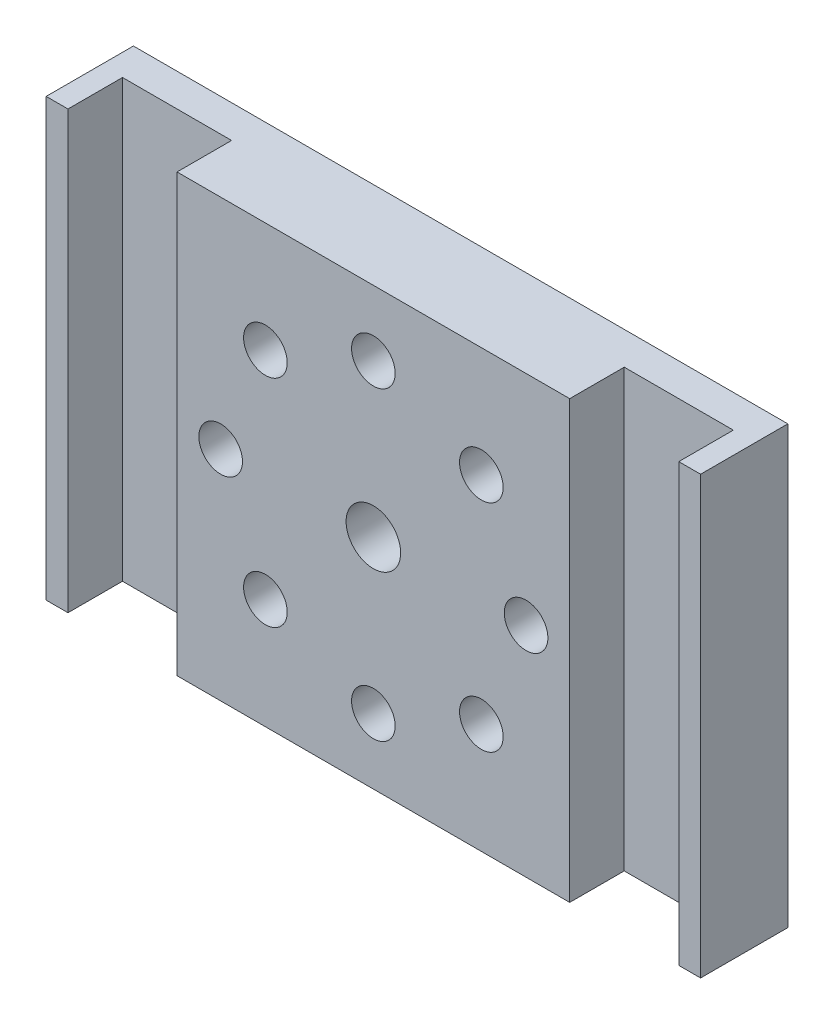
from build123d import *

# Parameters (mm, degrees)
ESQUISSE1_W      = 60
ESQUISSE1_H      = 40
ESQUISSE1_R      = 2.5
ESQUISSE1_R_2    = 2
EXTRUSION1_DEPTH = 8
ESQUISSE2_R      = 4
EXTRUSION2_DEPTH = 4
ESQUISSE3_R      = 2
EXTRUSION3_DEPTH = 15
ESQUISSE4_W      = 10
ESQUISSE4_H      = 5
EXTRUSION4_DEPTH = 41


with BuildPart() as part:
    # Esquisse1 → Extrusion1 (new body)
    with BuildSketch(Plane.XY):
        Rectangle(ESQUISSE1_W, ESQUISSE1_H)
        Circle(ESQUISSE1_R, mode=Mode.SUBTRACT)
        with Locations((9.899494937, 9.899494937)):
            Circle(ESQUISSE1_R_2, mode=Mode.SUBTRACT)
        with Locations((0, 14)):
            Circle(ESQUISSE1_R_2, mode=Mode.SUBTRACT)
        with Locations((14, 0)):
            Circle(ESQUISSE1_R_2, mode=Mode.SUBTRACT)
        with Locations((9.899494937, -9.899494937)):
            Circle(ESQUISSE1_R_2, mode=Mode.SUBTRACT)
        with Locations((0, -14)):
            Circle(ESQUISSE1_R_2, mode=Mode.SUBTRACT)
        with Locations((-9.899494937, -9.899494937)):
            Circle(ESQUISSE1_R_2, mode=Mode.SUBTRACT)
        with Locations((-14, 0)):
            Circle(ESQUISSE1_R_2, mode=Mode.SUBTRACT)
        with Locations((-9.899494937, 9.899494937)):
            Circle(ESQUISSE1_R_2, mode=Mode.SUBTRACT)
    extrude(amount=EXTRUSION1_DEPTH)

    # Esquisse2 → Extrusion2 (cut)
    with BuildSketch(Plane.XY):
        Circle(ESQUISSE2_R)
    extrude(amount=EXTRUSION2_DEPTH, mode=Mode.SUBTRACT)

    # Esquisse3 → Extrusion3 (cut)
    with BuildSketch(Plane.XZ.offset(20)):
        with Locations((-15.5, 4)):
            Circle(ESQUISSE3_R)
        with Locations((15.5, 4)):
            Circle(ESQUISSE3_R)
    extrude(amount=-EXTRUSION3_DEPTH, mode=Mode.SUBTRACT)

    # Esquisse4 → Extrusion4 (cut, through all)
    with BuildSketch(Plane(origin=(0, 20, 0), x_dir=(1, 0, 0), z_dir=(0, 1, 0))):
        with Locations((-23, -5.5)):
            Rectangle(ESQUISSE4_W, ESQUISSE4_H)
        with Locations((23, -5.5)):
            Rectangle(ESQUISSE4_W, ESQUISSE4_H)
    extrude(amount=-EXTRUSION4_DEPTH, mode=Mode.SUBTRACT)


solid = part.part
